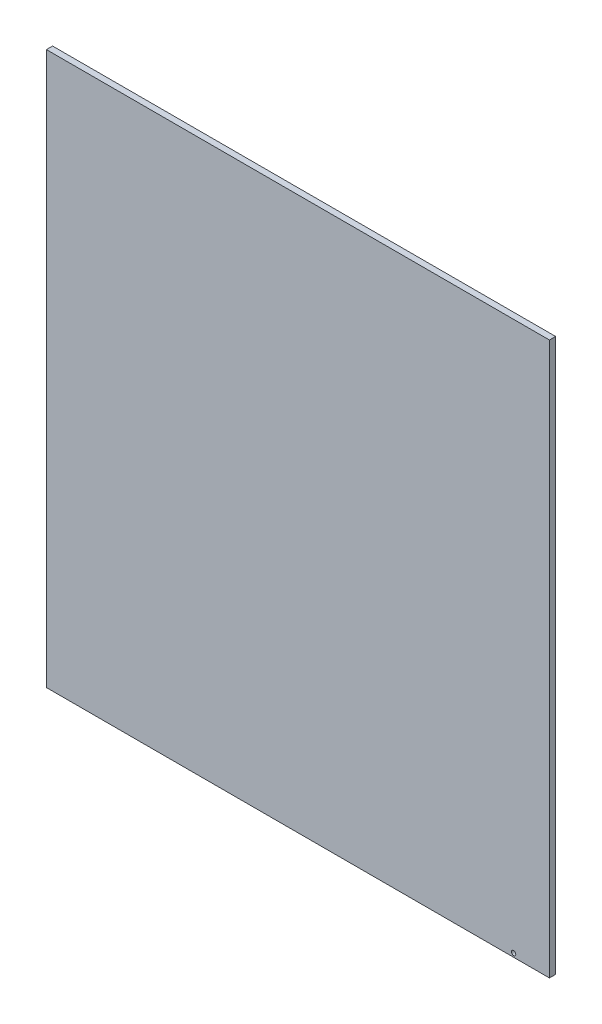
from build123d import *

# Parameters (mm, degrees)
SKETCH1_W           = 407
SKETCH1_H           = 450
BOSS_EXTRUDE1_DEPTH = 5
SKETCH4_R           = 1.75
CUT_EXTRUDE3_DEPTH  = 6
SKETCH5_W           = 406.880604732
SKETCH5_H           = 4
BOSS_EXTRUDE2_DEPTH = 5
SKETCH6_R           = 1.75
CUT_EXTRUDE4_DEPTH  = 6
SKETCH7_W           = 407
SKETCH7_H           = 7
CUT_EXTRUDE5_DEPTH  = 10


with BuildPart() as part:
    # Sketch1 → Boss-Extrude1 (new body)
    with BuildSketch(Plane.XY):
        with Locations((203.5, 225)):
            Rectangle(SKETCH1_W, SKETCH1_H)
    extrude(amount=BOSS_EXTRUDE1_DEPTH)

    # Sketch4 → Cut-Extrude3 (cut, through all)
    with BuildSketch(Plane(origin=(0, 0, 0), x_dir=(-1, 0, 0), z_dir=(0, 0, -1))):
        with Locations((-378, 447)):
            Circle(SKETCH4_R)
    extrude(amount=-CUT_EXTRUDE3_DEPTH, mode=Mode.SUBTRACT)

    # Sketch5 → Boss-Extrude2 (add)
    with BuildSketch(Plane(origin=(0, 0, 0), x_dir=(-1, 0, 0), z_dir=(0, 0, -1))):
        with Locations((-203.559697634, -2)):
            Rectangle(SKETCH5_W, SKETCH5_H)
    extrude(amount=-BOSS_EXTRUDE2_DEPTH)

    # Sketch6 → Cut-Extrude4 (cut, through all)
    with BuildSketch(Plane(origin=(0, 0, 0), x_dir=(-1, 0, 0), z_dir=(0, 0, -1))):
        with Locations((-378, -1)):
            Circle(SKETCH6_R)
    extrude(amount=-CUT_EXTRUDE4_DEPTH, mode=Mode.SUBTRACT)

    # Sketch7 → Cut-Extrude5 (cut)
    with BuildSketch(Plane.XY.offset(5)):
        with Locations((203.5, 446.5)):
            Rectangle(SKETCH7_W, SKETCH7_H)
    extrude(amount=-CUT_EXTRUDE5_DEPTH, mode=Mode.SUBTRACT)


solid = part.part
